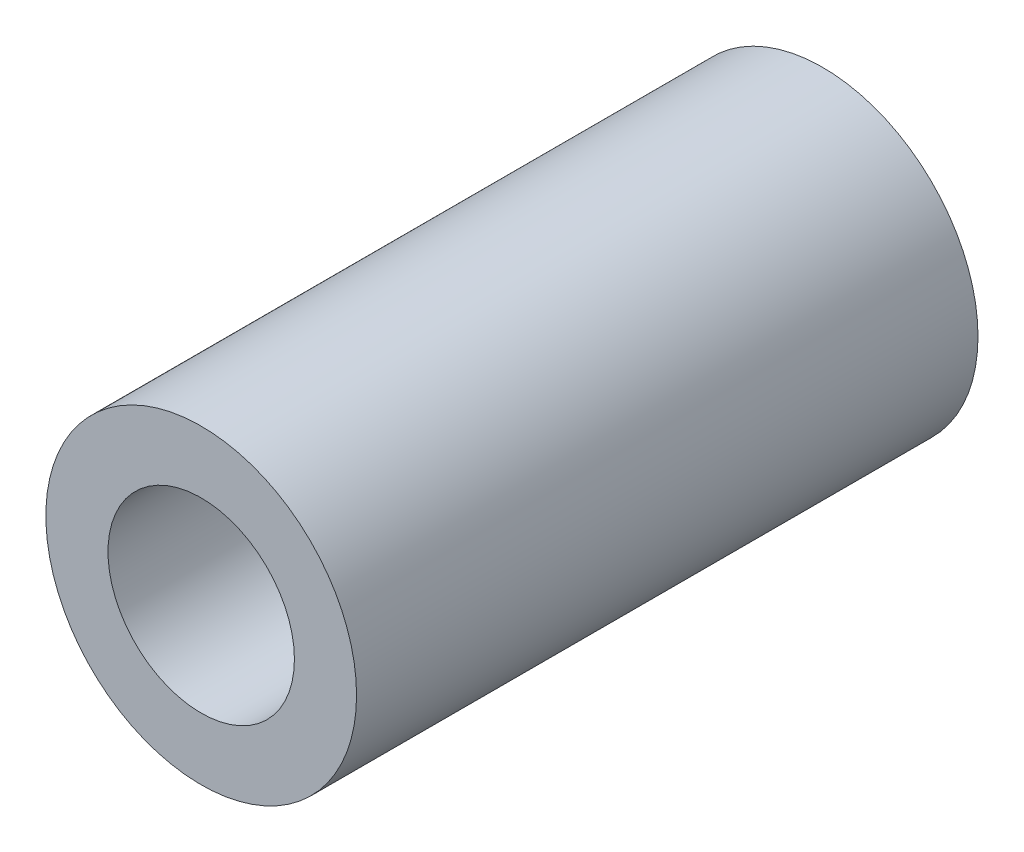
from build123d import *

# Parameters (mm, degrees)
SKETCH_1_R      = 2.5
SKETCH_1_R_2    = 1.5
EXTRUDE_1_DEPTH = 5


with BuildPart() as part:
    # 草图1 → 凸台-拉伸1 (new body, symmetric)
    with BuildSketch(Plane.XY):
        Circle(SKETCH_1_R)
        Circle(SKETCH_1_R_2, mode=Mode.SUBTRACT)
    extrude(amount=EXTRUDE_1_DEPTH, both=True)


solid = part.part
